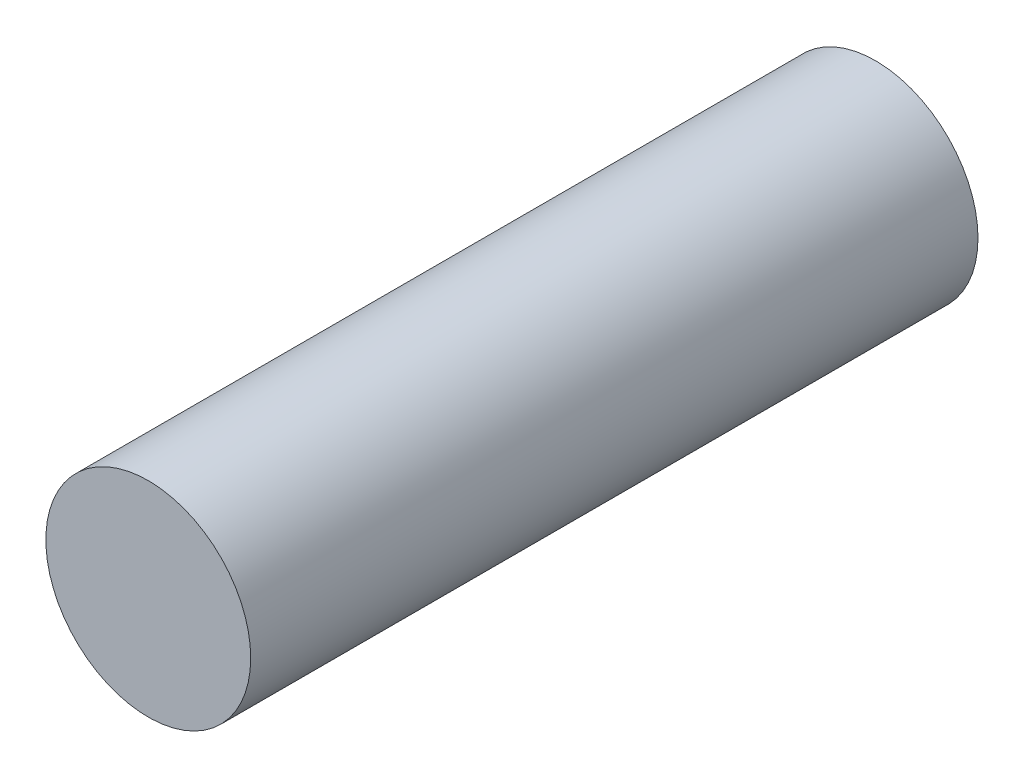
from build123d import *

# Parameters (mm, degrees)
SKETCH_1_R      = 20
EXTRUDE_1_DEPTH = 142


with BuildPart() as part:
    # 草图1 → 凸台-拉伸1 (new body)
    with BuildSketch(Plane.XY):
        Circle(SKETCH_1_R)
    extrude(amount=-EXTRUDE_1_DEPTH)


solid = part.part
